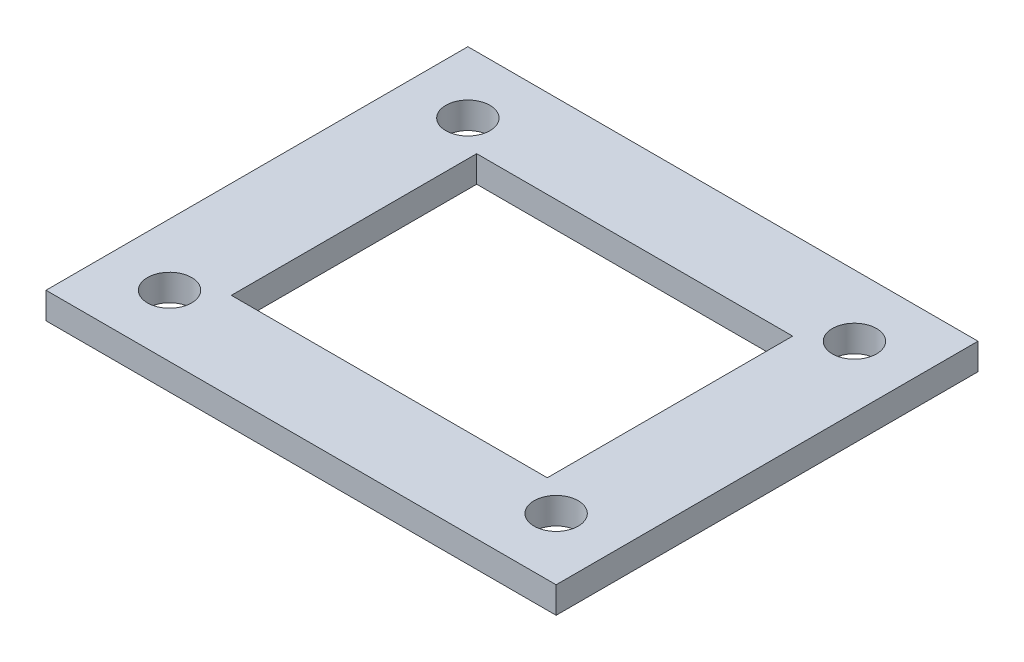
from build123d import *

# Parameters (mm, degrees)
SKETCH1_W                                = 49.8
SKETCH1_H                                = 39.8
BOSS_EXTRUDE1_DEPTH                      = 3
CUT_EXTRUDE1_DEPTH                       = 3
MIRROR1_AT_THE_SECOND_PLANE_COPY_1_DEPTH = 3
SKETCH3_W                                = 35.8
SKETCH3_H                                = 27.8
CUT_EXTRUDE2_DEPTH                       = 3
SKETCH4_W                                = 57.8
SKETCH4_H                                = 47.8
SKETCH4_W_2                              = 49.8
SKETCH4_H_2                              = 39.8
BOSS_EXTRUDE2_DEPTH                      = 3


with BuildPart() as part:
    # Sketch1 → Boss-Extrude1 (new body)
    with BuildSketch(Plane(origin=(0, 0, 0), x_dir=(1, 0, 0), z_dir=(0, 1, 0))):
        Rectangle(SKETCH1_W, SKETCH1_H)
    extrude(amount=BOSS_EXTRUDE1_DEPTH)

    # Sketch2 → Cut-Extrude1 (cut)
    with BuildSketch(Plane(origin=(0, 3, 0), x_dir=(1, 0, 0), z_dir=(0, 1, 0))):
        with BuildLine():
            ThreePointArc((-21.9, 14.4), (-20.132233047, 15.132233047), (-19.4, 16.9))
            Line((-19.4, 16.9), (-21.9, 16.9))
            Line((-21.9, 16.9), (-21.9, 14.4))
        make_face()
        with BuildLine():
            Line((-21.9, 16.9), (-19.4, 16.9))
            ThreePointArc((-19.4, 16.9), (-23.667766953, 18.667766953), (-21.9, 14.4))
            Line((-21.9, 14.4), (-21.9, 16.9))
        make_face()
    cut_extrude1 = extrude(amount=-CUT_EXTRUDE1_DEPTH, mode=Mode.SUBTRACT)

    # Mirror1: Cut-Extrude1 across plane
    add(cut_extrude1.mirror(Plane(origin=(0, 0, 0), x_dir=(0, 0, 1), z_dir=(1, 0, 0))), mode=Mode.SUBTRACT)

    # Mirror1 at the second plane: Cut-Extrude1 across plane
    add(cut_extrude1.mirror(Plane(origin=(0, 0, 0), x_dir=(1, 0, 0), z_dir=(0, 0, -1))), mode=Mode.SUBTRACT)

    # Mirror1 at the second plane copy 1 sketc → Mirror1 at the second plane copy 1 (cut)
    with BuildSketch(Plane(origin=(0, 3, 0), x_dir=(-1, 0, 0), z_dir=(0, 1, 0))):
        with BuildLine():
            ThreePointArc((-21.9, 14.4), (-20.132233047, 15.132233047), (-19.4, 16.9))
            Line((-19.4, 16.9), (-21.9, 16.9))
            Line((-21.9, 16.9), (-21.9, 14.4))
        make_face()
        with BuildLine():
            Line((-21.9, 16.9), (-19.4, 16.9))
            ThreePointArc((-19.4, 16.9), (-23.667766953, 18.667766953), (-21.9, 14.4))
            Line((-21.9, 14.4), (-21.9, 16.9))
        make_face()
    extrude(amount=-MIRROR1_AT_THE_SECOND_PLANE_COPY_1_DEPTH, mode=Mode.SUBTRACT)

    # Sketch3 → Cut-Extrude2 (cut)
    with BuildSketch(Plane(origin=(0, 3, 0), x_dir=(1, 0, 0), z_dir=(0, 1, 0))):
        Rectangle(SKETCH3_W, SKETCH3_H)
    extrude(amount=-CUT_EXTRUDE2_DEPTH, mode=Mode.SUBTRACT)

    # Sketch4 → Boss-Extrude2 (add)
    with BuildSketch(Plane(origin=(0, 3, 0), x_dir=(1, 0, 0), z_dir=(0, 1, 0))):
        Rectangle(SKETCH4_W, SKETCH4_H)
        Rectangle(SKETCH4_W_2, SKETCH4_H_2, mode=Mode.SUBTRACT)
    extrude(amount=-BOSS_EXTRUDE2_DEPTH)


solid = part.part
